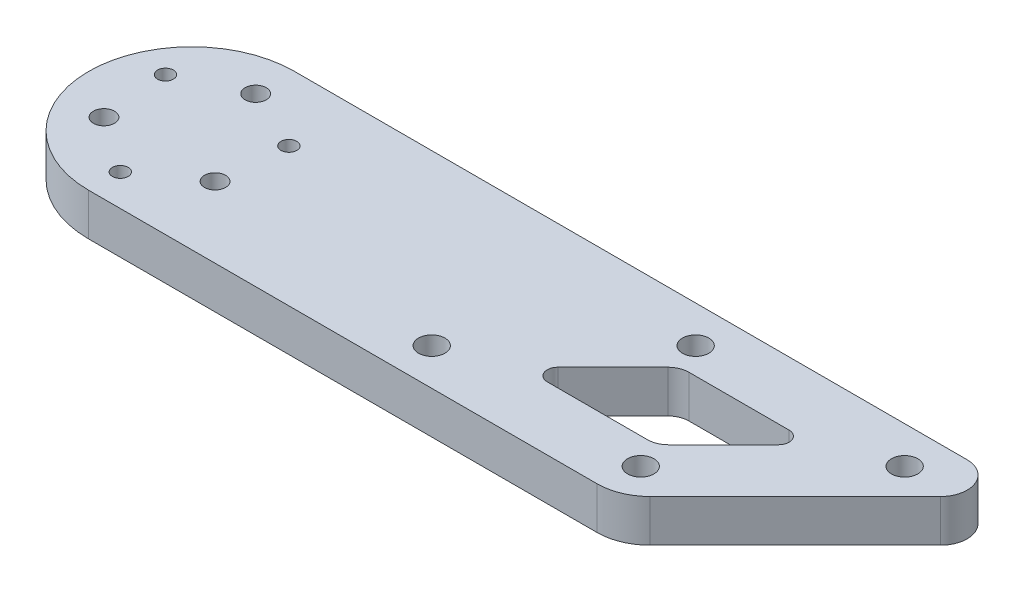
from build123d import *

# Parameters (mm, degrees)
SKETCH_1_R               = 2
SKETCH_1_R_2             = 1.5
EXTRUDE_1_DEPTH          = 8
CUT_EXTRUDE_1_DEPTH      = 9
SKETCH_3_R               = 2.5
CUT_EXTRUDE_2_DEPTH      = 1
CUT_EXTRUDE_2_DEPTH_BACK = 9


with BuildPart() as part:
    # 草图1 → 凸台-拉伸1 (new body)
    with BuildSketch(Plane(origin=(0, 0, 0), x_dir=(1, 0, 0), z_dir=(0, 1, 0))):
        with BuildLine():
            Line((0, 19.5), (127.428932188, 19.5))
            ThreePointArc((127.428932188, 19.5), (132.048329851, 16.413417162), (130.964466094, 10.964466094))
            Line((130.964466094, 10.964466094), (103.428932188, -16.571067812))
            ThreePointArc((103.428932188, -16.571067812), (100.1846987, -18.738795325), (96.357864376, -19.5))
            Line((96.357864376, -19.5), (0, -19.5))
            ThreePointArc((0, -19.5), (-19.5, 0), (0, 19.5))
        make_face()
        with Locations((0, 12.15)):
            Circle(SKETCH_1_R, mode=Mode.SUBTRACT)
        with Locations((-10.522208656, -6.075)):
            Circle(SKETCH_1_R, mode=Mode.SUBTRACT)
        with Locations((10.522208656, -6.075)):
            Circle(SKETCH_1_R, mode=Mode.SUBTRACT)
        with Locations((-11.691342951, 6.75)):
            Circle(SKETCH_1_R_2, mode=Mode.SUBTRACT)
        with Locations((11.691342951, 6.75)):
            Circle(SKETCH_1_R_2, mode=Mode.SUBTRACT)
        with Locations((0, -13.5)):
            Circle(SKETCH_1_R_2, mode=Mode.SUBTRACT)
    extrude(amount=EXTRUDE_1_DEPTH)

    # 草图2 → 切除-拉伸1 (cut, through all)
    with BuildSketch(Plane.XZ):
        with BuildLine():
            Line((93.872583002, 7.5), (74.902020254, 7.5))
            ThreePointArc((74.902020254, 7.5), (73.054261189, 6.265366865), (73.487806691, 4.085786438))
            Line((73.487806691, 4.085786438), (83.902020254, -6.328427125))
            ThreePointArc((83.902020254, -6.328427125), (85.199713649, -7.19551813), (86.730447378, -7.5))
            Line((86.730447378, -7.5), (105.701010127, -7.5))
            ThreePointArc((105.701010127, -7.5), (107.548769192, -6.265366865), (107.115223689, -4.085786438))
            Line((107.115223689, -4.085786438), (96.701010127, 6.328427125))
            ThreePointArc((96.701010127, 6.328427125), (95.403316731, 7.19551813), (93.872583002, 7.5))
        make_face()
    extrude(amount=-CUT_EXTRUDE_1_DEPTH, mode=Mode.SUBTRACT)

    # 草图3 → 切除-拉伸2 (cut, two sides)
    with BuildSketch(Plane.XZ) as cut_extrude_2_sk:
        with Locations((97.600505063, 12.5)):
            Circle(SKETCH_3_R)
        with Locations((122.600505063, -12.5)):
            Circle(SKETCH_3_R)
        with Locations((83.002525317, -12.5)):
            Circle(SKETCH_3_R)
        with Locations((58.002525317, 12.5)):
            Circle(SKETCH_3_R)
    extrude(amount=CUT_EXTRUDE_2_DEPTH, mode=Mode.SUBTRACT)
    extrude(cut_extrude_2_sk.sketch, amount=-CUT_EXTRUDE_2_DEPTH_BACK, mode=Mode.SUBTRACT)


solid = part.part
